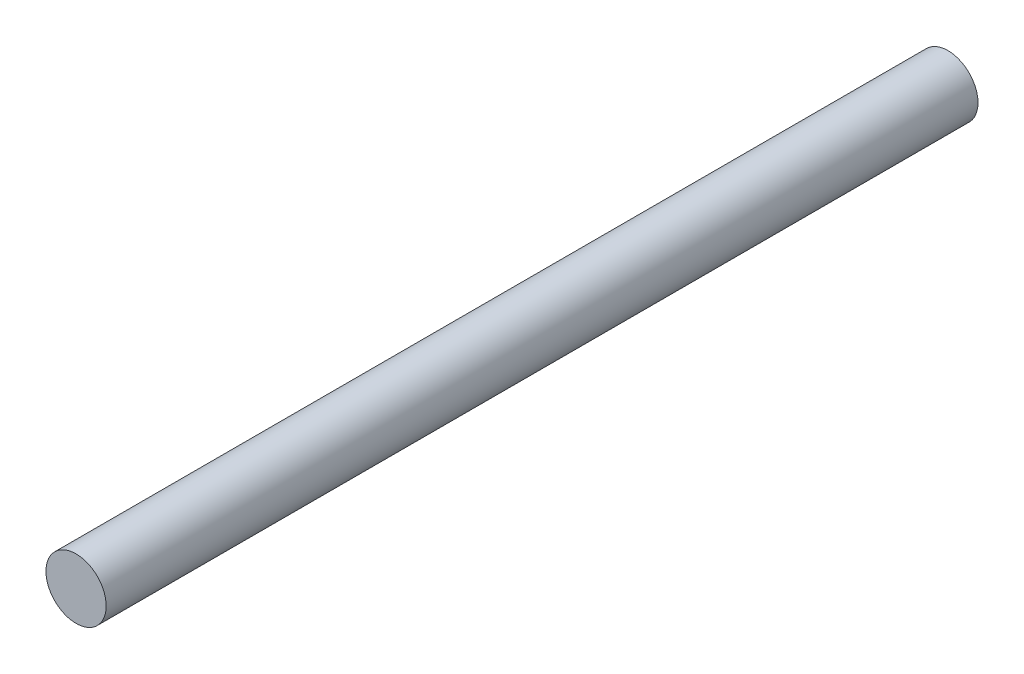
from build123d import *

# Parameters (mm, degrees)
SKETCH1_R           = 3.8
BOSS_EXTRUDE1_DEPTH = 110


with BuildPart() as part:
    # Sketch1 → Boss-Extrude1 (new body)
    with BuildSketch(Plane.XY):
        Circle(SKETCH1_R)
    extrude(amount=BOSS_EXTRUDE1_DEPTH)


solid = part.part
